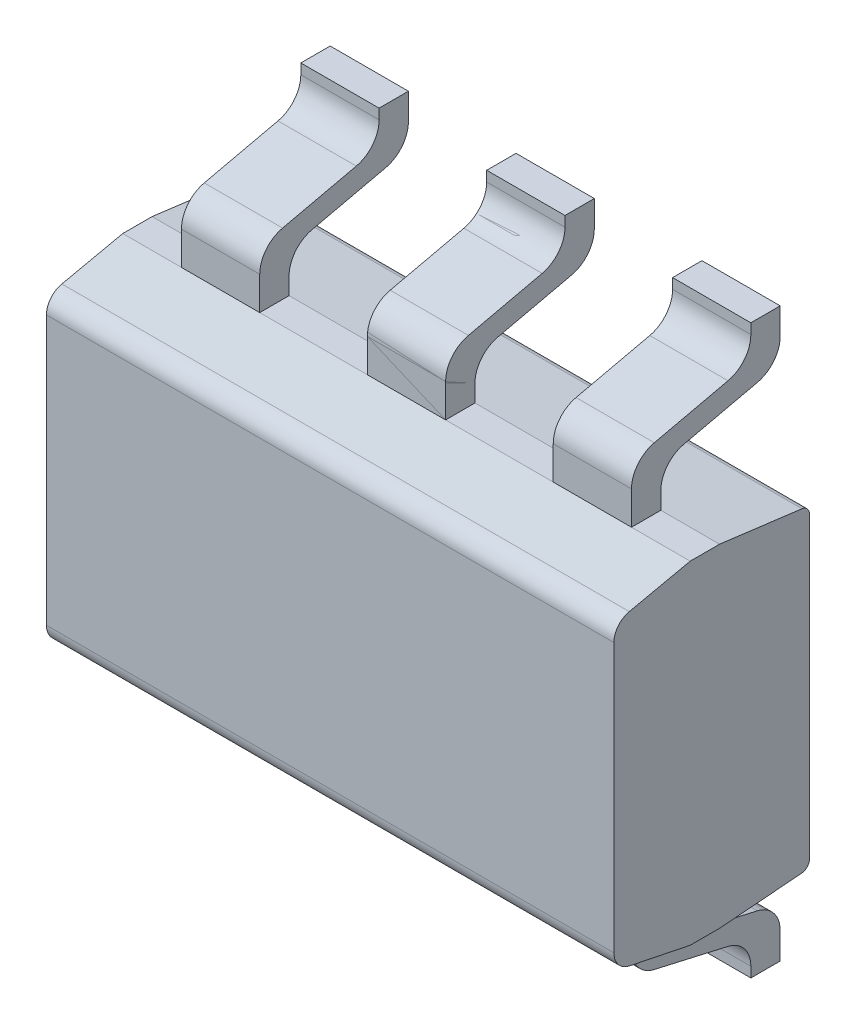
from build123d import *

# Parameters (mm, degrees)
ESQUISSE1_W                     = 2.9
ESQUISSE1_H                     = 1.7
BOSS_EXTRU_1_DEPTH              = 0.075
BOSS_EXTRU_2_DEPTH              = 1.45
BOSS_EXTRU_3_DEPTH              = 0.2
R_P_TITION_LIN_AIRE1_COUNT      = 2
R_P_TITION_LIN_AIRE1_PITCH      = 0.95
R_P_TITION_LIN_AIRE1_COUNT_DIR2 = 2
R_P_TITION_LIN_AIRE1_PITCH_DIR2 = 0.95
SYM_TRIE1_COPY_1_DEPTH          = 0.2
SYM_TRIE1_COPY_2_DEPTH          = 0.2
SYM_TRIE1_COPY_3_DEPTH          = 0.2


with BuildPart() as part:
    # Esquisse1 → Boss.-Extru.1 (new body, symmetric)
    with BuildSketch(Plane.XY):
        Rectangle(ESQUISSE1_W, ESQUISSE1_H)
    extrude(amount=BOSS_EXTRU_1_DEPTH, both=True)

    # Esquisse3 → Boss.-Extru.2 (add, symmetric)
    with BuildSketch(Plane(origin=(0, 0, 0), x_dir=(0, 0, -1), z_dir=(1, 0, 0))):
        with BuildLine():
            Line((0.075, 0.85), (0.075, -0.85))
            Line((0.075, -0.85), (0.494172018, -0.815996143))
            ThreePointArc((0.494172018, -0.815996143), (0.523234947, -0.801834814), (0.535, -0.771722017))
            Line((0.535, -0.771722017), (0.535, 0.752220004))
            ThreePointArc((0.535, 0.752220004), (0.52391745, 0.781575433), (0.496199925, 0.796282676))
            Line((0.496199925, 0.796282676), (0.075, 0.85))
        make_face()
        with BuildLine():
            Line((-0.075, 0.85), (-0.075, -0.85))
            Line((-0.075, -0.85), (-0.385091212, -0.78640211))
            ThreePointArc((-0.385091212, -0.78640211), (-0.4424891, -0.751650671), (-0.465, -0.688441183))
            Line((-0.465, -0.688441183), (-0.465, 0.684700545))
            ThreePointArc((-0.465, 0.684700545), (-0.442852126, 0.747462369), (-0.38621907, 0.782423373))
            Line((-0.38621907, 0.782423373), (-0.075, 0.85))
        make_face()
    extrude(amount=BOSS_EXTRU_2_DEPTH, both=True)


with BuildPart() as body_2:
    # Esquisse5 → Boss.-Extru.3 (new body, symmetric)
    with BuildSketch(Plane(origin=(0, 0, 0), x_dir=(0, 0, -1), z_dir=(1, 0, 0))):
        with BuildLine():
            Line((-0.075, 0.85), (-0.075, 1.019617275))
            ThreePointArc((-0.075, 1.019617275), (-0.042272533, 1.113143491), (0.041628708, 1.165858025))
            Line((0.041628708, 1.165858025), (0.418371292, 1.251828501))
            ThreePointArc((0.418371292, 1.251828501), (0.502272533, 1.304543034), (0.535, 1.39806925))
            Line((0.535, 1.39806925), (0.535, 1.45))
            Line((0.535, 1.45), (0.685, 1.45))
            Line((0.685, 1.45), (0.685, 1.315513616))
            ThreePointArc((0.685, 1.315513616), (0.652272533, 1.2219874), (0.568371292, 1.169272867))
            Line((0.568371292, 1.169272867), (0.191628708, 1.083302391))
            ThreePointArc((0.191628708, 1.083302391), (0.107727467, 1.030587857), (0.075, 0.937061641))
            Line((0.075, 0.937061641), (0.075, 0.85))
            Line((0.075, 0.85), (-0.075, 0.85))
        make_face()
    boss_extru_3 = extrude(amount=BOSS_EXTRU_3_DEPTH, both=True)


with BuildPart() as r_p_tition_lin_aire1_1:
    # Répétition linéaire1: Boss.-Extru.3 2 × 2
    with Locations(*[Vector(-1, 0, 0) * (i * R_P_TITION_LIN_AIRE1_PITCH) + Vector(1, 0, 0) * (j * R_P_TITION_LIN_AIRE1_PITCH_DIR2) for i in range(R_P_TITION_LIN_AIRE1_COUNT) for j in range(R_P_TITION_LIN_AIRE1_COUNT_DIR2) if (i, j) != (0, 0)]):
        add(boss_extru_3)


with BuildPart() as part_1:
    add(part.part)

    # Symétrie1: Boss.-Extru.3 across plane
    add(boss_extru_3.mirror(Plane.ZX))

    # Symétrie1 copy 1 sketch → Symétrie1 copy 1 (add, symmetric)
    with BuildSketch(Plane(origin=(0.95, 0, 0), x_dir=(0, 0, -1), z_dir=(1, 0, 0))):
        with BuildLine():
            Line((-0.075, -0.85), (-0.075, -1.019617275))
            ThreePointArc((-0.075, -1.019617275), (-0.042272533, -1.113143491), (0.041628708, -1.165858025))
            Line((0.041628708, -1.165858025), (0.418371292, -1.251828501))
            ThreePointArc((0.418371292, -1.251828501), (0.502272533, -1.304543034), (0.535, -1.39806925))
            Line((0.535, -1.39806925), (0.535, -1.45))
            Line((0.535, -1.45), (0.685, -1.45))
            Line((0.685, -1.45), (0.685, -1.315513616))
            ThreePointArc((0.685, -1.315513616), (0.652272533, -1.2219874), (0.568371292, -1.169272867))
            Line((0.568371292, -1.169272867), (0.191628708, -1.083302391))
            ThreePointArc((0.191628708, -1.083302391), (0.107727467, -1.030587857), (0.075, -0.937061641))
            Line((0.075, -0.937061641), (0.075, -0.85))
            Line((0.075, -0.85), (-0.075, -0.85))
        make_face()
    extrude(amount=SYM_TRIE1_COPY_1_DEPTH, both=True)

    # Symétrie1 copy 2 sketch → Symétrie1 copy 2 (add, symmetric)
    with BuildSketch(Plane(origin=(-0.95, 0, 0), x_dir=(0, 0, -1), z_dir=(1, 0, 0))):
        with BuildLine():
            Line((-0.075, -0.85), (-0.075, -1.019617275))
            ThreePointArc((-0.075, -1.019617275), (-0.042272533, -1.113143491), (0.041628708, -1.165858025))
            Line((0.041628708, -1.165858025), (0.418371292, -1.251828501))
            ThreePointArc((0.418371292, -1.251828501), (0.502272533, -1.304543034), (0.535, -1.39806925))
            Line((0.535, -1.39806925), (0.535, -1.45))
            Line((0.535, -1.45), (0.685, -1.45))
            Line((0.685, -1.45), (0.685, -1.315513616))
            ThreePointArc((0.685, -1.315513616), (0.652272533, -1.2219874), (0.568371292, -1.169272867))
            Line((0.568371292, -1.169272867), (0.191628708, -1.083302391))
            ThreePointArc((0.191628708, -1.083302391), (0.107727467, -1.030587857), (0.075, -0.937061641))
            Line((0.075, -0.937061641), (0.075, -0.85))
            Line((0.075, -0.85), (-0.075, -0.85))
        make_face()
    extrude(amount=SYM_TRIE1_COPY_2_DEPTH, both=True)

    # Symétrie1 copy 3 sketch → Symétrie1 copy 3 (add, symmetric)
    with BuildSketch(Plane(origin=(0, 0, 0), x_dir=(0, 0, -1), z_dir=(1, 0, 0))):
        with BuildLine():
            Line((-0.075, -0.85), (-0.075, -1.019617275))
            ThreePointArc((-0.075, -1.019617275), (-0.042272533, -1.113143491), (0.041628708, -1.165858025))
            Line((0.041628708, -1.165858025), (0.418371292, -1.251828501))
            ThreePointArc((0.418371292, -1.251828501), (0.502272533, -1.304543034), (0.535, -1.39806925))
            Line((0.535, -1.39806925), (0.535, -1.45))
            Line((0.535, -1.45), (0.685, -1.45))
            Line((0.685, -1.45), (0.685, -1.315513616))
            ThreePointArc((0.685, -1.315513616), (0.652272533, -1.2219874), (0.568371292, -1.169272867))
            Line((0.568371292, -1.169272867), (0.191628708, -1.083302391))
            ThreePointArc((0.191628708, -1.083302391), (0.107727467, -1.030587857), (0.075, -0.937061641))
            Line((0.075, -0.937061641), (0.075, -0.85))
            Line((0.075, -0.85), (-0.075, -0.85))
        make_face()
    extrude(amount=SYM_TRIE1_COPY_3_DEPTH, both=True)


solid = Compound([body_2.part, r_p_tition_lin_aire1_1.part, part_1.part])
